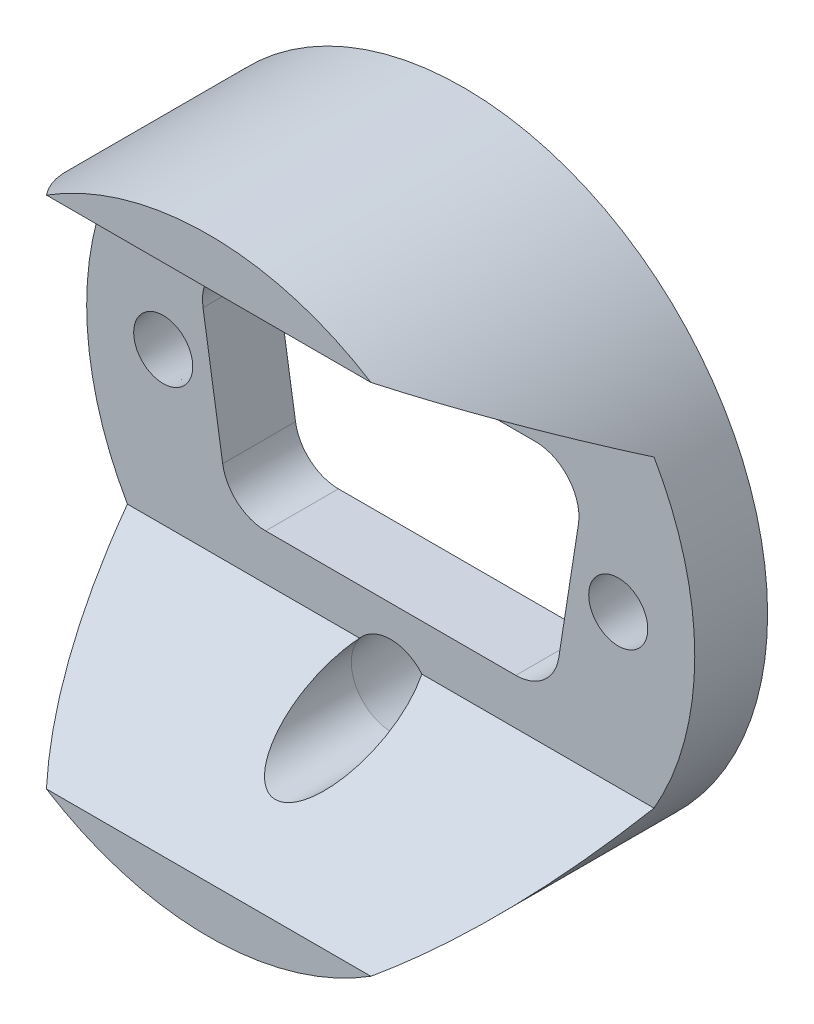
from build123d import *

# Parameters (mm, degrees)
SKETCH1_R           = 16.7
BOSS_EXTRUDE1_DEPTH = 14
SKETCH2_W           = 38.1
SKETCH2_H           = 12.7
CUT_EXTRUDE1_DEPTH  = 10
CUT_EXTRUDE2_DEPTH  = 5
SKETCH4_R           = 2.1844
CUT_EXTRUDE9_DEPTH  = 15
CUT_EXTRUDE9_TAPER  = 8
CUT_EXTRUDE10_DEPTH = 34.4
SKETCH7_R           = 2.7813
CUT_EXTRUDE11_DEPTH = 3.937
CUT_EXTRUDE11_TAPER = 8
SKETCH8_R           = 2.227990734
CUT_EXTRUDE12_DEPTH = 11.063


with BuildPart() as part:
    # Sketch1 → Boss-Extrude1 (new body)
    with BuildSketch(Plane.XY):
        Circle(SKETCH1_R)
    extrude(amount=BOSS_EXTRUDE1_DEPTH)

    # Sketch2 → Cut-Extrude1 (cut)
    with BuildSketch(Plane.XY.offset(14)):
        Rectangle(SKETCH2_W, SKETCH2_H)
    extrude(amount=-CUT_EXTRUDE1_DEPTH, mode=Mode.SUBTRACT)

    # Sketch3 → Cut-Extrude2 (cut, through all)
    with BuildSketch(Plane.XY.offset(4)):
        with BuildLine():
            ThreePointArc((-6.8707, -5.8293), (-8.422701629, -5.256066199), (-9.229469724, -3.811617761))
            Line((-9.229469724, -3.811617761), (-10.308969724, 3.071782239))
            ThreePointArc((-10.308969724, 3.071782239), (-9.764566199, 4.993701629), (-7.9502, 5.8293))
            Line((-7.9502, 5.8293), (7.9502, 5.8293))
            ThreePointArc((7.9502, 5.8293), (9.764566199, 4.993701629), (10.308969724, 3.071782239))
            Line((10.308969724, 3.071782239), (9.229469724, -3.811617761))
            ThreePointArc((9.229469724, -3.811617761), (8.422701629, -5.256066199), (6.8707, -5.8293))
            Line((6.8707, -5.8293), (-6.8707, -5.8293))
        make_face()
    extrude(amount=-CUT_EXTRUDE2_DEPTH, mode=Mode.SUBTRACT)

    # Sketch4 → Cut-Extrude9 (cut, through all)
    with BuildSketch(Plane(origin=(0, 0, 0), x_dir=(-1, 0, 0), z_dir=(0, 0, -1))):
        with Locations((-12.4968, 0)):
            Circle(SKETCH4_R)
        with Locations((12.496796773, -0.0127)):
            Circle(SKETCH4_R)
    extrude(amount=-CUT_EXTRUDE9_DEPTH, taper=CUT_EXTRUDE9_TAPER, mode=Mode.SUBTRACT)

    # Sketch6 → Cut-Extrude10 (cut, through all)
    with BuildSketch(Plane(origin=(16.7, 0, 0), x_dir=(0, 0, -1), z_dir=(1, 0, 0))):
        Polygon((-4, 8.35), (-14, 14.123502692), (-14, 6.35), (-4, 6.35), align=None)
        Polygon((-4, -6.35), (-4, -8.35), (-14, -14.123502692), (-14, -6.35), align=None)
    extrude(amount=-CUT_EXTRUDE10_DEPTH, mode=Mode.SUBTRACT)

    # Sketch7 → Cut-Extrude11 (cut)
    with BuildSketch(Plane(origin=(0, 0, 0), x_dir=(-1, 0, 0), z_dir=(0, 0, -1))):
        with Locations((0, 9.779)):
            Circle(SKETCH7_R)
        with Locations((0, -9.779)):
            Circle(SKETCH7_R)
    extrude(amount=-CUT_EXTRUDE11_DEPTH, taper=CUT_EXTRUDE11_TAPER, mode=Mode.SUBTRACT)

    # Sketch8 → Cut-Extrude12 (cut, through all)
    with BuildSketch(Plane(origin=(0, 0, 3.937), x_dir=(-1, 0, 0), z_dir=(0, 0, -1))):
        with Locations((0, -9.779)):
            Circle(SKETCH8_R)
        with Locations((0, 9.779)):
            Circle(SKETCH8_R)
    extrude(amount=-CUT_EXTRUDE12_DEPTH, mode=Mode.SUBTRACT)


solid = part.part
